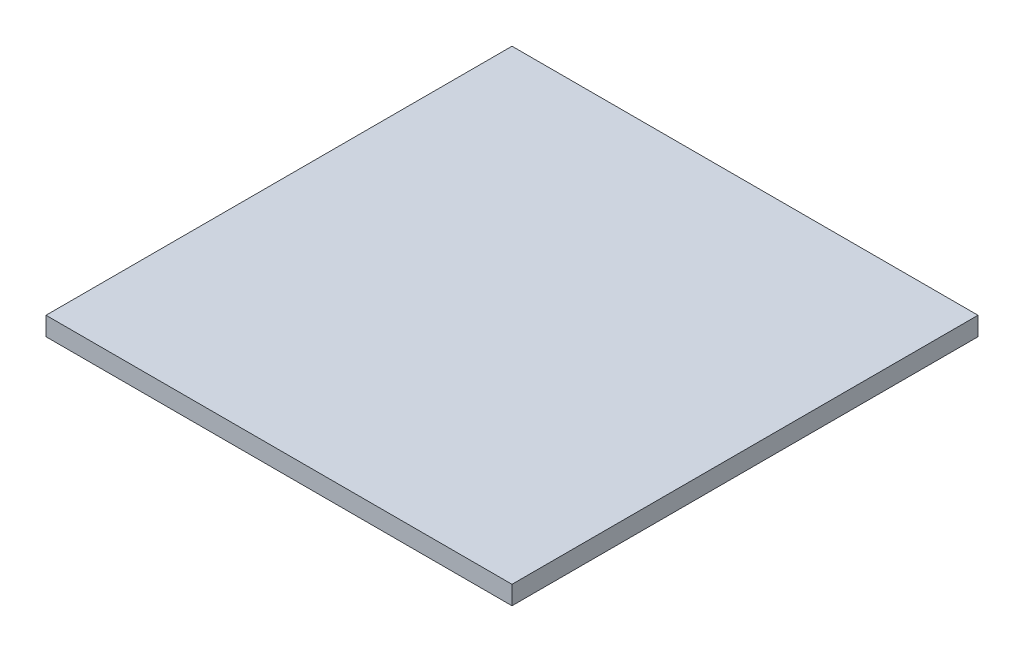
from build123d import *

# Parameters (mm, degrees)
SKETCH_1_W      = 50
SKETCH_1_H      = 50
EXTRUDE_1_DEPTH = 2


with BuildPart() as part:
    # 草图1 → 凸台-拉伸1 (new body)
    with BuildSketch(Plane(origin=(0, 0, 0), x_dir=(1, 0, 0), z_dir=(0, 1, 0))):
        Rectangle(SKETCH_1_W, SKETCH_1_H)
    extrude(amount=EXTRUDE_1_DEPTH)


solid = part.part
